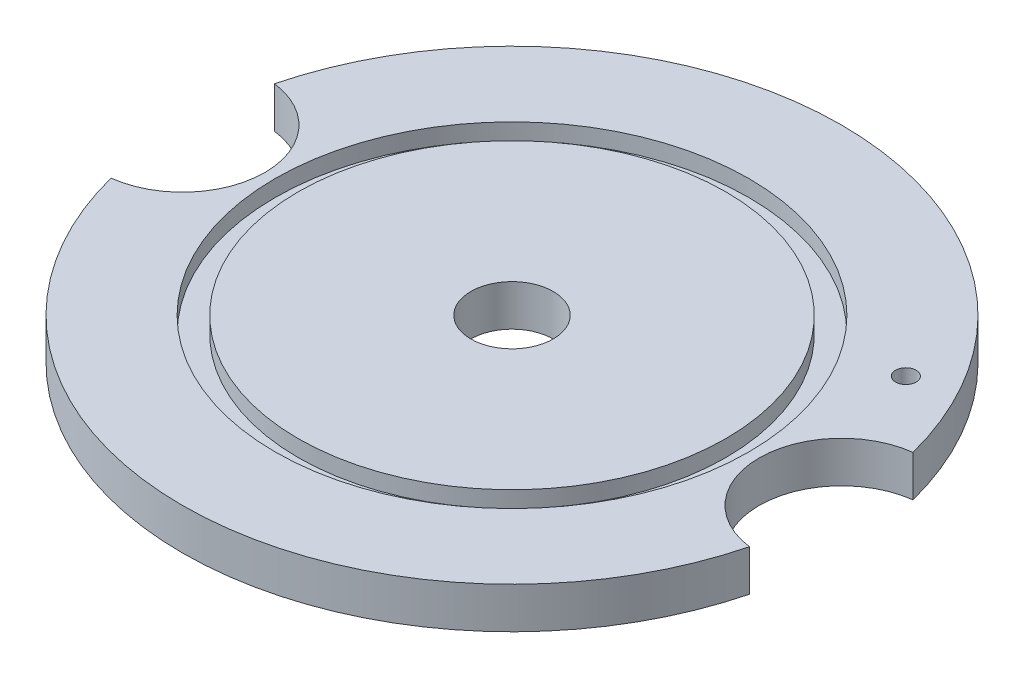
from build123d import *

# Parameters (mm, degrees)
F_1_2_0_5_DIAMETER_HOLE1_D   = 12.7
F_1_1_DIAMETER_HOLE1_D       = 25.4
F_1_8_0_125_DIAMETER_HOLE1_D = 3.175


with BuildPart() as part:
    # Sketch1 → Revolve1 (revolve)
    with BuildSketch(Plane.XY):
        Polygon((-32.9565, 6.35), (-32.9565, 3.81), (-36.5125, 3.81), (-36.5125, 6.35), (-50.8, 6.35), (-50.8, 0), (0, 0), (0, 6.35), align=None)
    revolve(axis=Axis((0, 0, 0), (0, 1, 0)))

    # 1/2 (0.5) Diameter Hole1 (through all)
    with Locations(Plane(origin=(0, 6.35, 0), x_dir=(1, 0, 0), z_dir=(0, 1, 0))):
        with Locations((0, 0)):
            Hole(F_1_2_0_5_DIAMETER_HOLE1_D / 2)

    # 1 (1) Diameter Hole1 (through all)
    with Locations(Plane(origin=(0, 6.35, 0), x_dir=(1, 0, 0), z_dir=(0, 1, 0))):
        with Locations((50.8, 0), (-50.8, 0)):
            Hole(F_1_1_DIAMETER_HOLE1_D / 2)

    # 1/8 (0.125) Diameter Hole1 (through all)
    with Locations(Plane(origin=(0, 6.35, 0), x_dir=(1, 0, 0), z_dir=(0, 1, 0))):
        with Locations((38.494829198, 22.225)):
            Hole(F_1_8_0_125_DIAMETER_HOLE1_D / 2)


solid = part.part
